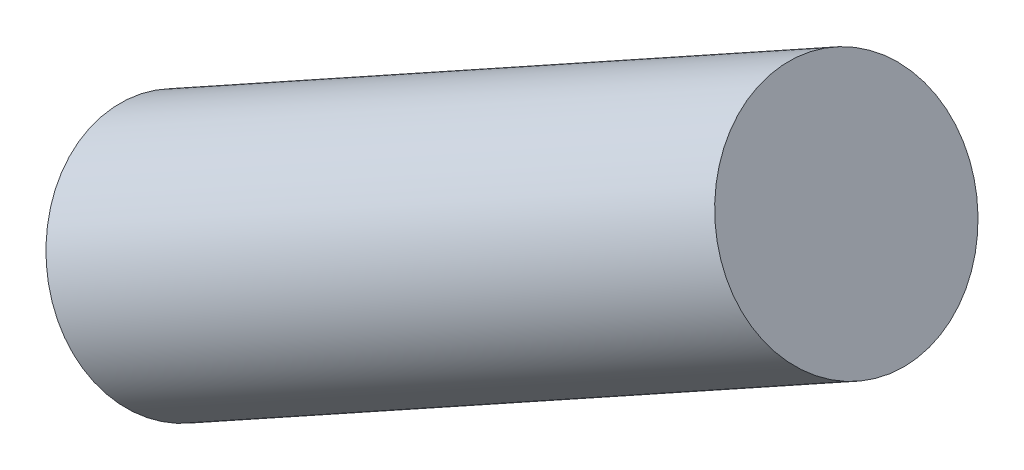
from build123d import *

# Parameters (mm, degrees)
SWEEP1_PROFILE_R = 46.5


with BuildPart() as part:
    # Sweep1: sweep along a path in Sketch2
    with BuildLine(Plane.XY) as sweep1_path:
        Line((193.385912142, 182.052886074), (-69, 36.61))
    # Sweep1 profile (on start of the path) → Sweep1 (sweep)
    with BuildSketch(Plane(origin=(193.385912142, 182.052886074, 0), x_dir=(0.48480962, -0.874619707, 0), z_dir=(-0.874619707, -0.48480962, 0))):
        Circle(SWEEP1_PROFILE_R)
    sweep(path=sweep1_path.line)


solid = part.part
